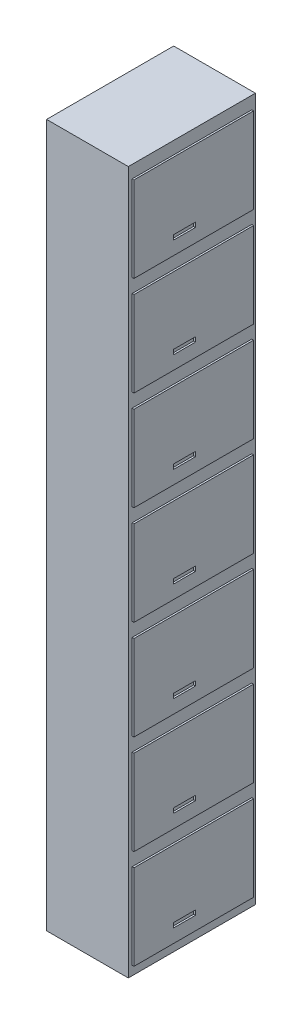
from build123d import *

# Parameters (mm, degrees)
SKETCH1_W           = 450
SKETCH1_H           = 3870
BOSS_EXTRUDE1_DEPTH = 700
SKETCH3_W           = 658.862952103
SKETCH3_H           = 470
SKETCH3_W_2         = 121.072841775
SKETCH3_H_2         = 25.802408902
SKETCH3_H_3         = 25.802408903
BOSS_EXTRUDE3_DEPTH = 10


with BuildPart() as part:
    # Sketch1 → Boss-Extrude1 (new body)
    with BuildSketch(Plane.XY):
        with Locations((88.061970043, 2244.986327315)):
            Rectangle(SKETCH1_W, SKETCH1_H)
    extrude(amount=BOSS_EXTRUDE1_DEPTH)

    # Sketch3 → Boss-Extrude3 (add)
    with BuildSketch(Plane(origin=(313.061970043, 0, 0), x_dir=(0, 0, -1), z_dir=(1, 0, 0))):
        with Locations((-349.431476051, 594.986327315)):
            Rectangle(SKETCH3_W, SKETCH3_H)
        with Locations((-401.128332344, 446.85045415)):
            Rectangle(SKETCH3_W_2, SKETCH3_H_2, mode=Mode.SUBTRACT)
        with Locations((-349.431476051, 1141.758813467)):
            Rectangle(SKETCH3_W, SKETCH3_H)
        with Locations((-401.128332344, 993.622940303)):
            Rectangle(SKETCH3_W_2, SKETCH3_H_3, mode=Mode.SUBTRACT)
        with Locations((-349.431476051, 1688.531299619)):
            Rectangle(SKETCH3_W, SKETCH3_H)
        with Locations((-401.128332344, 1540.395426455)):
            Rectangle(SKETCH3_W_2, SKETCH3_H_3, mode=Mode.SUBTRACT)
        with Locations((-349.431476051, 2235.303785772)):
            Rectangle(SKETCH3_W, SKETCH3_H)
        with Locations((-401.128332344, 2087.167912607)):
            Rectangle(SKETCH3_W_2, SKETCH3_H_3, mode=Mode.SUBTRACT)
        with Locations((-349.431476051, 2782.076271924)):
            Rectangle(SKETCH3_W, SKETCH3_H)
        with Locations((-401.128332344, 2633.940398759)):
            Rectangle(SKETCH3_W_2, SKETCH3_H_3, mode=Mode.SUBTRACT)
        with Locations((-349.431476051, 3328.848758076)):
            Rectangle(SKETCH3_W, SKETCH3_H)
        with Locations((-401.128332344, 3180.712884911)):
            Rectangle(SKETCH3_W_2, SKETCH3_H_2, mode=Mode.SUBTRACT)
        with Locations((-349.431476051, 3875.621244228)):
            Rectangle(SKETCH3_W, SKETCH3_H)
        with Locations((-401.128332344, 3727.485371064)):
            Rectangle(SKETCH3_W_2, SKETCH3_H_3, mode=Mode.SUBTRACT)
    extrude(amount=BOSS_EXTRUDE3_DEPTH)


solid = part.part
